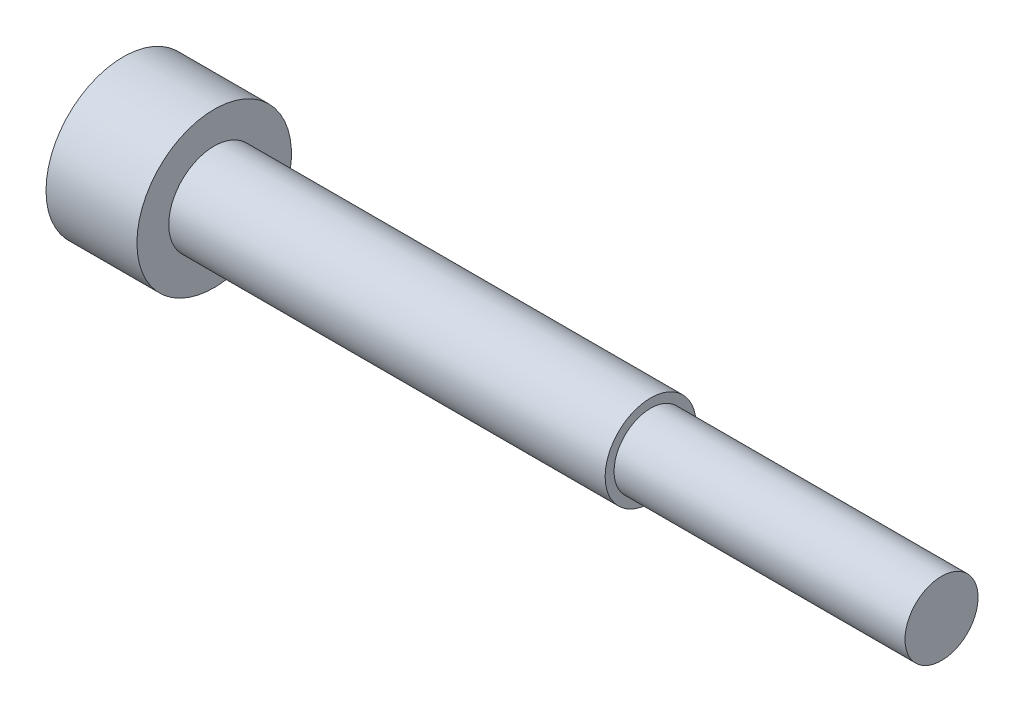
from build123d import *

# Parameters (mm, degrees)
SCHNITT_LINEAR_AUSTRAGEN1_DEPTH = 3.65
SKIZZE3_R                       = 2.5
AUFSATZ_LINEAR_AUSTRAGEN1_DEPTH = 24


with BuildPart() as part:
    # Skizze1 → Basis-Rotation (revolve)
    with BuildSketch(Plane.XY):
        Polygon((40, 0), (40, 2.0095), (0, 2.0095), (0, 4.25), (-5, 4.25), (-5, 0), align=None)
    revolve(axis=Axis((0, 0, 0), (1, 0, 0)))

    # Skizze2 → Schnitt-Linear austragen1 (cut)
    with BuildSketch(Plane.ZY.offset(5)):
        Polygon((2.309401077, 0), (1.154700538, 2), (-1.154700538, 2), (-2.309401077, 0), (-1.154700538, -2), (1.154700538, -2), align=None)
    extrude(amount=-SCHNITT_LINEAR_AUSTRAGEN1_DEPTH, mode=Mode.SUBTRACT)

    # Skizze3 → Aufsatz-Linear austragen1 (add)
    with BuildSketch(Plane(origin=(0, 0, 0), x_dir=(0, 0, -1), z_dir=(1, 0, 0))):
        Circle(SKIZZE3_R)
    extrude(amount=AUFSATZ_LINEAR_AUSTRAGEN1_DEPTH)


solid = part.part
